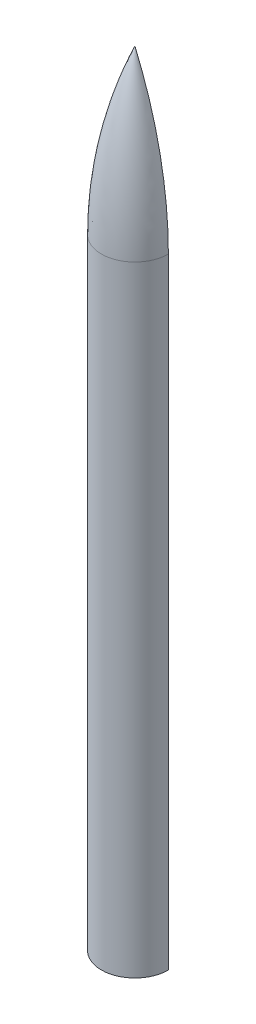
from build123d import *

# Parameters (mm, degrees)
REVOLVE1_ANGLE = 180


with BuildPart() as part:
    # Sketch3 → Revolve1 (revolve)
    with BuildSketch(Plane.XY):
        with BuildLine():
            Line((-137.16, 0), (-137.16, 2540))
            ThreePointArc((-137.16, 2540), (-102.51760351, 2881.724316349), (0, 3209.544))
            Line((0, 3209.544), (0, 3201.42777496))
            ThreePointArc((0, 3201.42777496), (-100.152000253, 2877.430986171), (-133.985, 2540))
            Line((-133.985, 2540), (-133.985, 0))
            Line((-133.985, 0), (-137.16, 0))
        make_face()
    revolve(axis=Axis((0, 0, 0), (0, 1, 0)), revolution_arc=REVOLVE1_ANGLE)


solid = part.part
